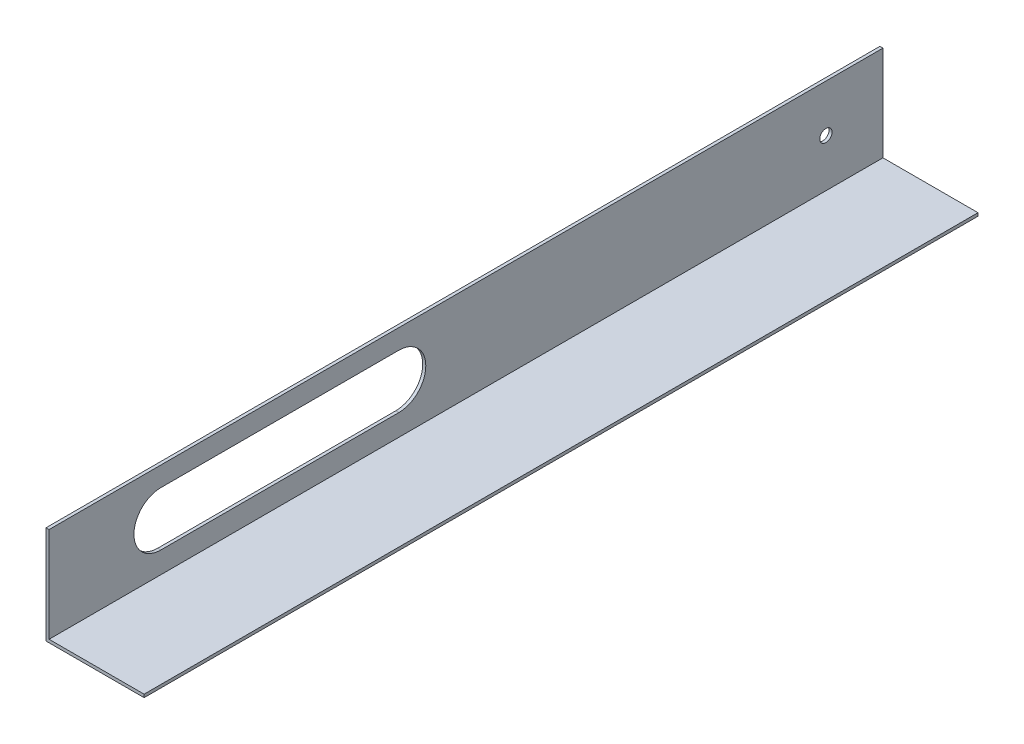
from build123d import *

# Parameters (mm, degrees)
BOSS_EXTRUDE2_DEPTH = 431.8
CUT_EXTRUDE3_DEPTH  = 127
SKETCH7_R           = 3.175
CUT_EXTRUDE4_DEPTH  = 127


with BuildPart() as part:
    # Sketch3 → Boss-Extrude2 (new body)
    with BuildSketch(Plane.XY):
        Polygon((0, 0), (0, 49.2125), (-1.5875, 49.2125), (-1.5875, -1.5875), (49.2125, -1.5875), (49.2125, 0), align=None)
    extrude(amount=BOSS_EXTRUDE2_DEPTH)

    # Sketch6 → Cut-Extrude3 (cut)
    with BuildSketch(Plane(origin=(0, 0, 0), x_dir=(0, 0, -1), z_dir=(1, 0, 0))):
        with BuildLine():
            Line((-373.888, 39.0525), (-250.698, 39.0525))
            ThreePointArc((-250.698, 39.0525), (-236.728, 25.0825), (-250.698, 11.1125))
            Line((-250.698, 11.1125), (-373.888, 11.1125))
            ThreePointArc((-373.888, 11.1125), (-387.858, 25.0825), (-373.888, 39.0525))
        make_face()
    extrude(amount=-CUT_EXTRUDE3_DEPTH, mode=Mode.SUBTRACT)

    # Sketch7 → Cut-Extrude4 (cut)
    with BuildSketch(Plane(origin=(0, 0, 0), x_dir=(0, 0, -1), z_dir=(1, 0, 0))):
        with Locations((-29.538792285, 24.773594829)):
            Circle(SKETCH7_R)
    extrude(amount=-CUT_EXTRUDE4_DEPTH, mode=Mode.SUBTRACT)


solid = part.part
